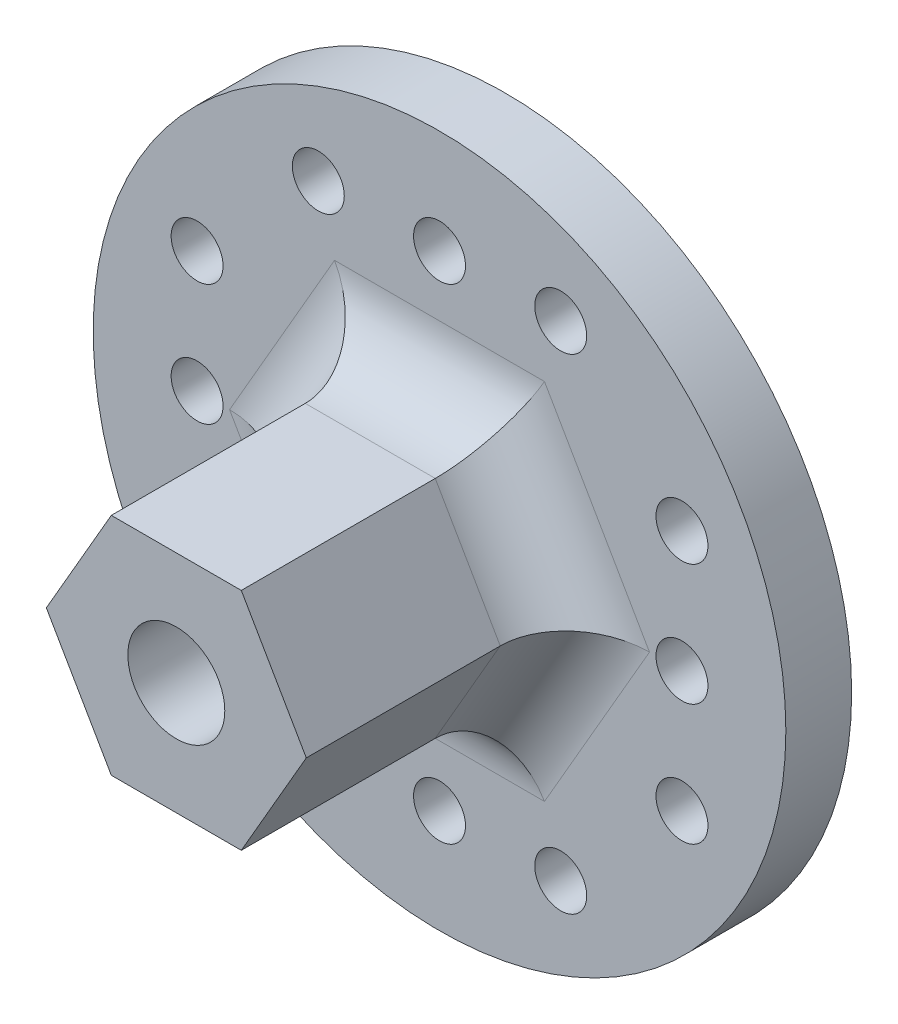
from build123d import *

# Parameters (mm, degrees)
SKETCH1_R           = 10
SKETCH1_R_2         = 0.75
BOSS_EXTRUDE1_DEPTH = 1.9
BOSS_EXTRUDE2_DEPTH = 7.6
SKETCH4_R           = 1.4
CUT_EXTRUDE2_DEPTH  = 5
FILLET1_R           = 2


with BuildPart() as part:
    # Sketch1 → Boss-Extrude1 (new body)
    with BuildSketch(Plane.XY):
        Circle(SKETCH1_R)
        with Locations((-7, 0)):
            Circle(SKETCH1_R_2, mode=Mode.SUBTRACT)
        with Locations((3.5, 7)):
            Circle(SKETCH1_R_2, mode=Mode.SUBTRACT)
        with Locations((0, 7)):
            Circle(SKETCH1_R_2, mode=Mode.SUBTRACT)
        with Locations((-3.5, 7)):
            Circle(SKETCH1_R_2, mode=Mode.SUBTRACT)
        with Locations((7, -3.5)):
            Circle(SKETCH1_R_2, mode=Mode.SUBTRACT)
        with Locations((7, 0)):
            Circle(SKETCH1_R_2, mode=Mode.SUBTRACT)
        with Locations((7, 3.5)):
            Circle(SKETCH1_R_2, mode=Mode.SUBTRACT)
        with Locations((-3.5, -7)):
            Circle(SKETCH1_R_2, mode=Mode.SUBTRACT)
        with Locations((0, -7)):
            Circle(SKETCH1_R_2, mode=Mode.SUBTRACT)
        with Locations((3.5, -7)):
            Circle(SKETCH1_R_2, mode=Mode.SUBTRACT)
        with Locations((-7, -3.5)):
            Circle(SKETCH1_R_2, mode=Mode.SUBTRACT)
        with Locations((-7, 3.5)):
            Circle(SKETCH1_R_2, mode=Mode.SUBTRACT)
    extrude(amount=BOSS_EXTRUDE1_DEPTH)

    # Sketch2 → Boss-Extrude2 (add)
    with BuildSketch(Plane.XY.offset(1.9)):
        Polygon((3.75277675, 0), (1.876388375, 3.25), (-1.876388375, 3.25), (-3.75277675, 0), (-1.876388375, -3.25), (1.876388375, -3.25), align=None)
    extrude(amount=BOSS_EXTRUDE2_DEPTH)

    # Sketch4 → Cut-Extrude2 (cut)
    with BuildSketch(Plane.XY.offset(9.5)):
        Circle(SKETCH4_R)
    extrude(amount=-CUT_EXTRUDE2_DEPTH, mode=Mode.SUBTRACT)

    # Sketch3 → Cut-Revolve1 (revolve, cut)
    with BuildSketch(Plane(origin=(0, 0, 0), x_dir=(-1, 0, 0), z_dir=(0, 0, -1))):
        with BuildLine():
            Line((-3.25, 0), (3.25, 0))
            ThreePointArc((3.25, 0), (0, -3.25), (-3.25, 0))
        make_face()
    revolve(axis=Axis((3.25, 0, 0), (-1, 0, 0)), mode=Mode.SUBTRACT)

    # Fillet1
    fillet1_edges = [part.edges().sort_by_distance(p)[0] for p in [
        (2.814582562, -1.625, 1.9),
        (2.814582562, 1.625, 1.9),
        (0, 3.25, 1.9),
        (-2.814582562, 1.625, 1.9),
        (-2.814582562, -1.625, 1.9),
        (0, -3.25, 1.9),
    ]]
    fillet(fillet1_edges, radius=FILLET1_R)


solid = part.part
